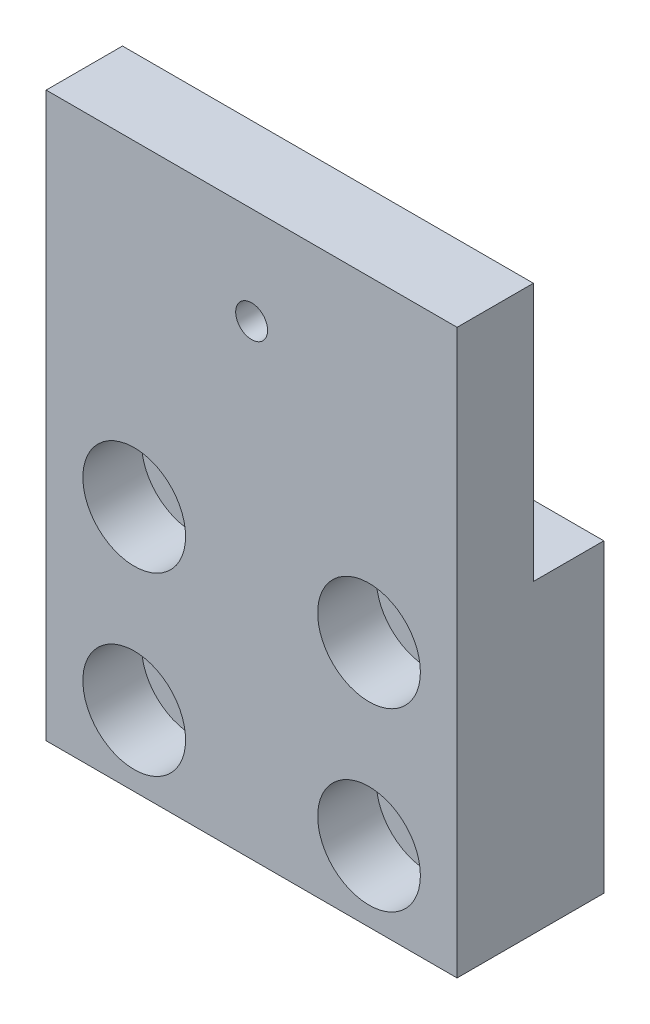
from build123d import *

# Parameters (mm, degrees)
SKETCH1_W                                        = 44.45
SKETCH1_H                                        = 60.96
BOSS_EXTRUDE1_DEPTH                              = 7.9375
CBORE_FOR_1_4_SOCKET_HEAD_CAP_SCREW1_D           = 6.7564
CBORE_FOR_1_4_SOCKET_HEAD_CAP_SCREW1_CBORE_D     = 11.1125
CBORE_FOR_1_4_SOCKET_HEAD_CAP_SCREW1_CBORE_DEPTH = 6.35
SKETCH4_W                                        = 7.62
SKETCH4_H                                        = 27.94
CUT_EXTRUDE1_DEPTH                               = 45.45
F_8_32_TAPPED_HOLE1_D                            = 3.4544


with BuildPart() as part:
    # Sketch1 → Boss-Extrude1 (new body, symmetric)
    with BuildSketch(Plane.XY):
        Rectangle(SKETCH1_W, SKETCH1_H)
    extrude(amount=BOSS_EXTRUDE1_DEPTH, both=True)

    # CBORE for 1/4 Socket Head Cap Screw1 (through all)
    with Locations(Plane.XY.offset(7.9375)):
        with Locations((-12.7, -3.81), (12.7, -3.81), (12.7, -22.86), (-12.7, -22.86)):
            CounterBoreHole(CBORE_FOR_1_4_SOCKET_HEAD_CAP_SCREW1_D / 2, CBORE_FOR_1_4_SOCKET_HEAD_CAP_SCREW1_CBORE_D / 2, CBORE_FOR_1_4_SOCKET_HEAD_CAP_SCREW1_CBORE_DEPTH)

    # Sketch4 → Cut-Extrude1 (cut, through all)
    with BuildSketch(Plane(origin=(22.225, 0, 0), x_dir=(0, 0, -1), z_dir=(1, 0, 0))):
        with Locations((4.1275, 16.51)):
            Rectangle(SKETCH4_W, SKETCH4_H)
    extrude(amount=-CUT_EXTRUDE1_DEPTH, mode=Mode.SUBTRACT)

    # #8-32 Tapped Hole1 (through all)
    with Locations(Plane.XY.offset(7.9375)):
        with Locations((0, 19.939)):
            Hole(F_8_32_TAPPED_HOLE1_D / 2)


solid = part.part
